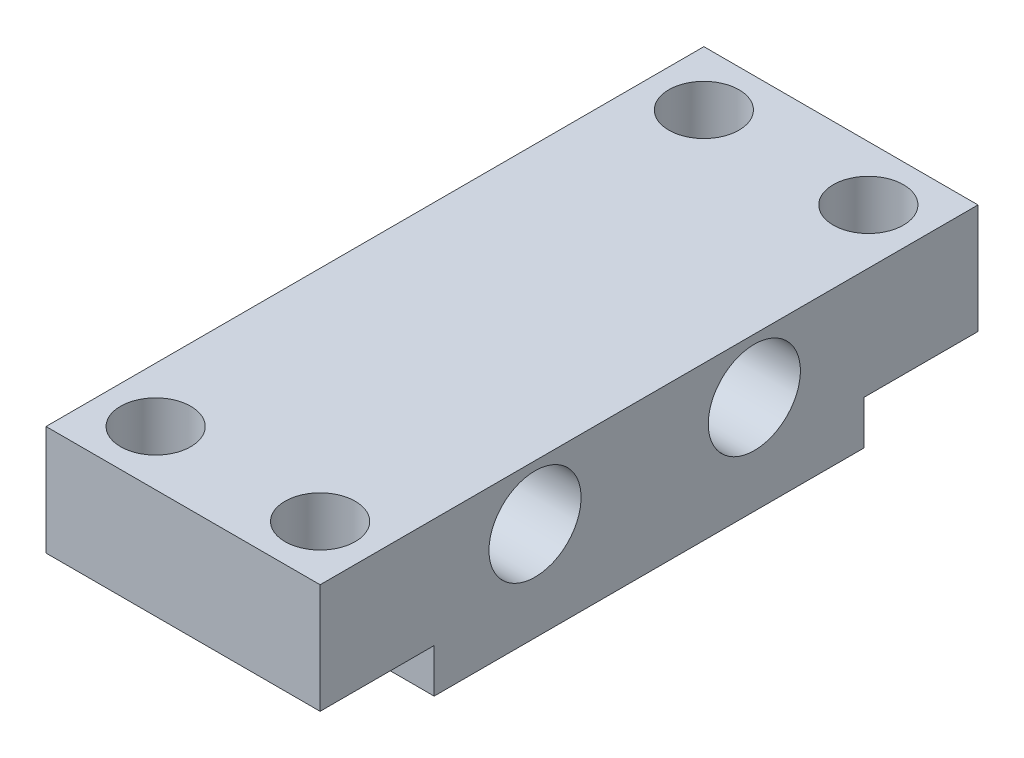
from build123d import *

# Parameters (mm, degrees)
SKETCH1_W           = 12.5
SKETCH1_H           = 30
BOSS_EXTRUDE1_DEPTH = 5
SKETCH2_W           = 12.5
SKETCH2_H           = 19.6
BOSS_EXTRUDE2_DEPTH = 2
SKETCH3_R           = 2.1
CUT_EXTRUDE1_DEPTH  = 15
SKETCH4_R           = 1.6
CUT_EXTRUDE2_DEPTH  = 10
LPATTERN1_COUNT     = 2
LPATTERN1_PITCH     = 7.5


with BuildPart() as part:
    # Sketch1 → Boss-Extrude1 (new body)
    with BuildSketch(Plane(origin=(0, 0, 0), x_dir=(1, 0, 0), z_dir=(0, 1, 0))):
        with Locations((6.25, 15)):
            Rectangle(SKETCH1_W, SKETCH1_H)
    extrude(amount=BOSS_EXTRUDE1_DEPTH)

    # Sketch2 → Boss-Extrude2 (add)
    with BuildSketch(Plane.XZ):
        with Locations((6.25, -15)):
            Rectangle(SKETCH2_W, SKETCH2_H)
    extrude(amount=BOSS_EXTRUDE2_DEPTH)

    # Sketch3 → Cut-Extrude1 (cut)
    with BuildSketch(Plane.ZY):
        with Locations((-19.8, 2.5)):
            Circle(SKETCH3_R)
        with Locations((-9.8, 2.5)):
            Circle(SKETCH3_R)
    extrude(amount=-CUT_EXTRUDE1_DEPTH, mode=Mode.SUBTRACT)

    # Sketch4 → Cut-Extrude2 (cut)
    with BuildSketch(Plane(origin=(0, 5, 0), x_dir=(1, 0, 0), z_dir=(0, 1, 0))):
        with Locations((2.5, 27.5)):
            Circle(SKETCH4_R)
        with Locations((2.5, 2.5)):
            Circle(SKETCH4_R)
    cut_extrude2 = extrude(amount=-CUT_EXTRUDE2_DEPTH, mode=Mode.SUBTRACT)

    # LPattern1: Cut-Extrude2 ×2
    with Locations(*[(i * LPATTERN1_PITCH, 0, 0) for i in range(1, LPATTERN1_COUNT)]):
        add(cut_extrude2, mode=Mode.SUBTRACT)


solid = part.part
